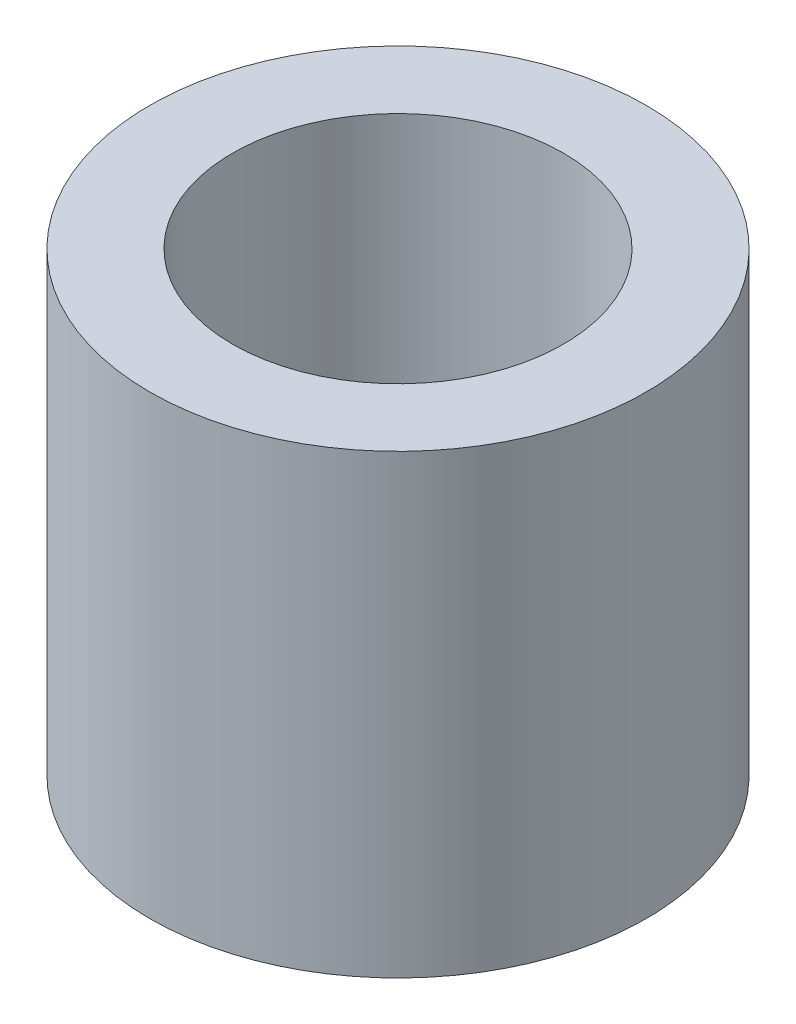
from build123d import *

# Parameters (mm, degrees)
SKETCH1_R           = 2.38125
SKETCH1_R_2         = 1.5875
BOSS_EXTRUDE1_DEPTH = 4.375


with BuildPart() as part:
    # Sketch1 → Boss-Extrude1 (new body)
    with BuildSketch(Plane(origin=(0, 0, 0), x_dir=(1, 0, 0), z_dir=(0, 1, 0))):
        Circle(SKETCH1_R)
        Circle(SKETCH1_R_2, mode=Mode.SUBTRACT)
    extrude(amount=BOSS_EXTRUDE1_DEPTH)


solid = part.part
